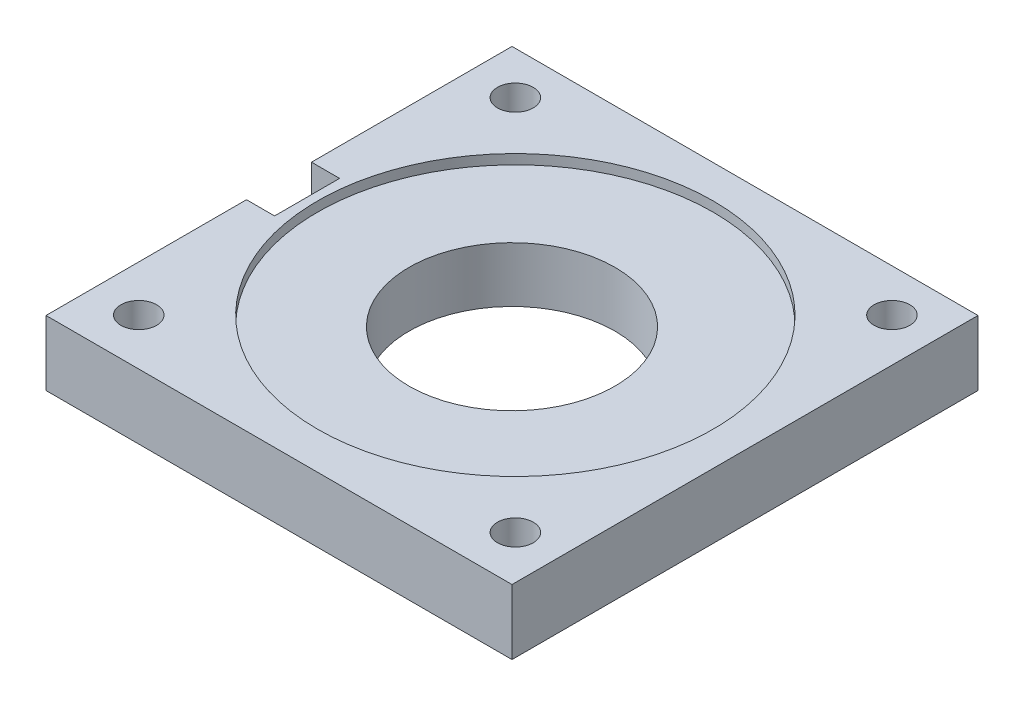
from build123d import *

# Parameters (mm, degrees)
SKETCH1_W           = 86
SKETCH1_H           = 86
SKETCH1_R           = 19
BOSS_EXTRUDE1_DEPTH = 12
CUT_EXTRUDE1_REACH  = 14
SKETCH2_R           = 3.3
SKETCH4_R           = 36.5
CUT_EXTRUDE2_DEPTH  = 1.8
SKETCH6_W           = 8.07061303
SKETCH6_H           = 12
CUT_EXTRUDE3_DEPTH  = 13


with BuildPart() as part:
    # Sketch1 → Boss-Extrude1 (new body)
    with BuildSketch(Plane(origin=(0, 0, 0), x_dir=(1, 0, 0), z_dir=(0, 1, 0))):
        Rectangle(SKETCH1_W, SKETCH1_H)
        Circle(SKETCH1_R, mode=Mode.SUBTRACT)
    extrude(amount=BOSS_EXTRUDE1_DEPTH)

    # Sketch2 → Cut-Extrude1 (cut, up to next)
    with BuildSketch(Plane(origin=(0, 12, 0), x_dir=(1, 0, 0), z_dir=(0, 1, 0)), mode=Mode.PRIVATE) as cut_extrude1_sk1:
        with Locations((-34.507589913, -34.373280458)):
            Circle(SKETCH2_R)
    cut_extrude1_tool1 = extrude(cut_extrude1_sk1.sketch, amount=-CUT_EXTRUDE1_REACH, mode=Mode.PRIVATE) & part.part
    add(cut_extrude1_tool1.solids().sort_by_distance((-34.50759, 12, 34.37328))[0], mode=Mode.SUBTRACT)
    # Sketch2 → Cut-Extrude1 (cut, up to next)
    with BuildSketch(Plane(origin=(0, 12, 0), x_dir=(1, 0, 0), z_dir=(0, 1, 0)), mode=Mode.PRIVATE) as cut_extrude1_sk2:
        with Locations((-34.507589913, 35.126719542)):
            Circle(SKETCH2_R)
    cut_extrude1_tool2 = extrude(cut_extrude1_sk2.sketch, amount=-CUT_EXTRUDE1_REACH, mode=Mode.PRIVATE) & part.part
    add(cut_extrude1_tool2.solids().sort_by_distance((-34.50759, 12, -35.12672))[0], mode=Mode.SUBTRACT)
    # Sketch2 → Cut-Extrude1 (cut, up to next)
    with BuildSketch(Plane(origin=(0, 12, 0), x_dir=(1, 0, 0), z_dir=(0, 1, 0)), mode=Mode.PRIVATE) as cut_extrude1_sk3:
        with Locations((34.992410087, -34.373280458)):
            Circle(SKETCH2_R)
    cut_extrude1_tool3 = extrude(cut_extrude1_sk3.sketch, amount=-CUT_EXTRUDE1_REACH, mode=Mode.PRIVATE) & part.part
    add(cut_extrude1_tool3.solids().sort_by_distance((34.99241, 12, 34.37328))[0], mode=Mode.SUBTRACT)
    # Sketch2 → Cut-Extrude1 (cut, up to next)
    with BuildSketch(Plane(origin=(0, 12, 0), x_dir=(1, 0, 0), z_dir=(0, 1, 0)), mode=Mode.PRIVATE) as cut_extrude1_sk4:
        with Locations((34.992410087, 35.126719542)):
            Circle(SKETCH2_R)
    cut_extrude1_tool4 = extrude(cut_extrude1_sk4.sketch, amount=-CUT_EXTRUDE1_REACH, mode=Mode.PRIVATE) & part.part
    add(cut_extrude1_tool4.solids().sort_by_distance((34.99241, 12, -35.12672))[0], mode=Mode.SUBTRACT)

    # Sketch4 → Cut-Extrude2 (cut)
    with BuildSketch(Plane(origin=(0, 12, 0), x_dir=(1, 0, 0), z_dir=(0, 1, 0))):
        with Locations((0.242410087, 0.376719542)):
            Circle(SKETCH4_R)
    extrude(amount=-CUT_EXTRUDE2_DEPTH, mode=Mode.SUBTRACT)

    # Sketch6 → Cut-Extrude3 (cut, through all)
    with BuildSketch(Plane(origin=(0, 12, 0), x_dir=(1, 0, 0), z_dir=(0, 1, 0))):
        with Locations((-41.851719536, 0)):
            Rectangle(SKETCH6_W, SKETCH6_H)
    extrude(amount=-CUT_EXTRUDE3_DEPTH, mode=Mode.SUBTRACT)


solid = part.part
